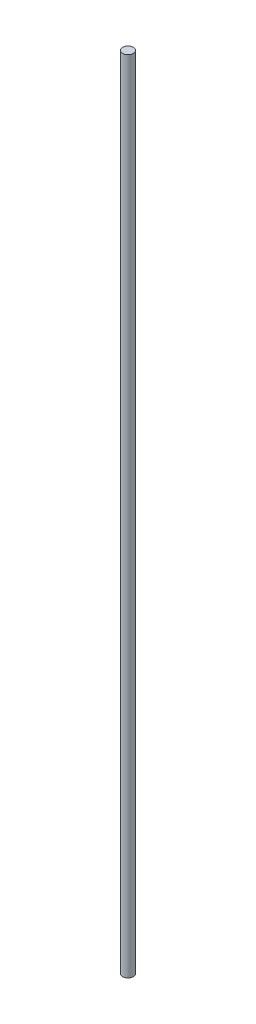
from build123d import *

# Parameters (mm, degrees)
SKETCH1_R           = 10
BOSS_EXTRUDE1_DEPTH = 1500


with BuildPart() as part:
    # Sketch1 → Boss-Extrude1 (new body)
    with BuildSketch(Plane(origin=(0, 0, 0), x_dir=(1, 0, 0), z_dir=(0, 1, 0))):
        Circle(SKETCH1_R)
    extrude(amount=BOSS_EXTRUDE1_DEPTH)


solid = part.part
